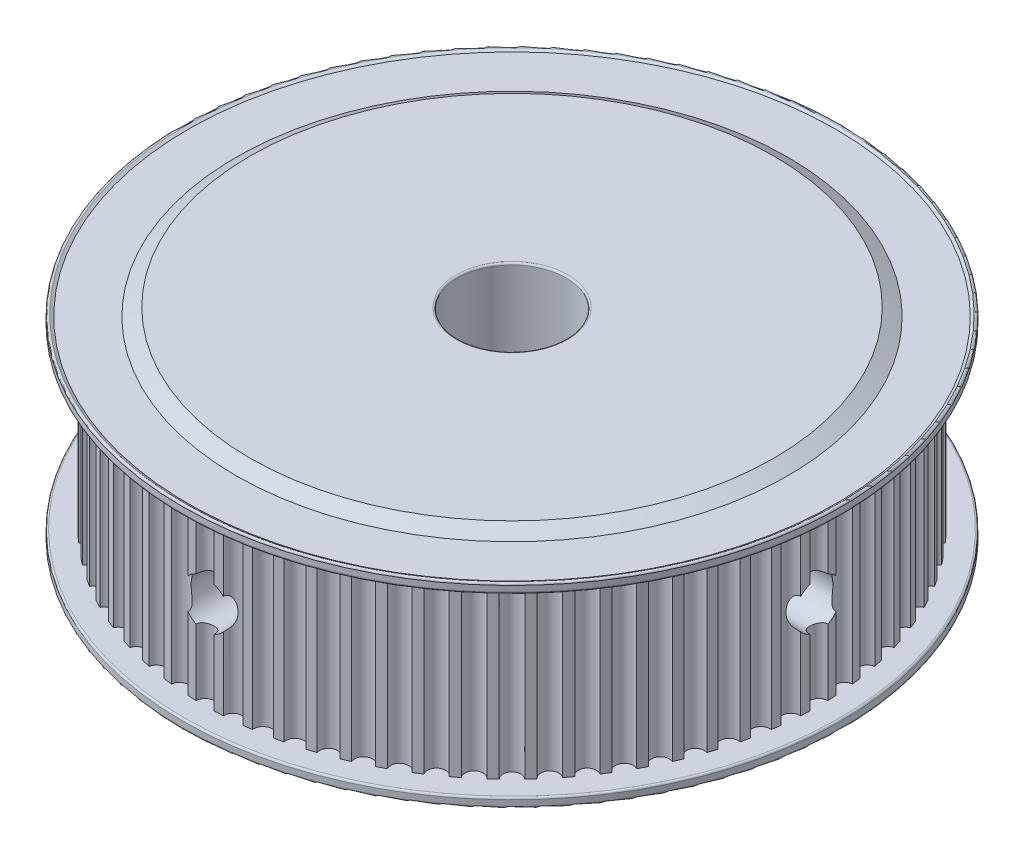
from build123d import *

# Parameters (mm, degrees)
FILLET1_R            = 0.2
BOSS_EXTRUDE1_DEPTH  = 19.5
FILLET1_OF_MIRROR1_R = 0.2
SKETCH4_R            = 2.6
CUT_EXTRUDE1_DEPTH   = 36.5
SKETCH5_R            = 2.6
CUT_EXTRUDE2_DEPTH   = 36.5
SKETCH3_R            = 6
CUT_EXTRUDE3_DEPTH   = 24
FILLET2_R            = 0.2
SCALE1_SCALE         = 0.5


with BuildPart() as part:
    # Sketch1 → Revolve1 (revolve)
    with BuildSketch(Plane.XY):
        Polygon((0, 0), (0, 1.75), (36.5, 1.75), (36.5, 0.55), (35.893782217, 0.9), (30.558845727, 0.9), (29, 0), align=None)
    revolve1 = revolve(axis=Axis((0, 0, 0), (0, 1, 0)))

    # Fillet1
    fillet1_edges = [part.edges().sort_by_distance(p)[0] for p in [
        (-36.5, 0.55, 0),
        (-36.5, 1.75, 0),
    ]]
    fillet(fillet1_edges, radius=FILLET1_R)

    # Sketch2 → Boss-Extrude1 (add)
    with BuildSketch(Plane(origin=(0, 1.75, 0), x_dir=(1, 0, 0), z_dir=(0, 1, 0))):
        with BuildLine():
            ThreePointArc((1.965926579, 33.943116131), (1.48305917, 33.967639534), (0.999891863, 33.985294118))
            ThreePointArc((0.999891863, 33.985294118), (0, 33), (-0.999891863, 33.985294118))
            ThreePointArc((-0.999891863, 33.985294118), (-1.48305917, 33.967639534), (-1.965926579, 33.943116131))
            ThreePointArc((-1.965926579, 33.943116131), (-2.876139511, 32.874425037), (-3.958100524, 33.768823495))
            ThreePointArc((-3.958100524, 33.768823495), (-4.437890535, 33.709125287), (-4.916783132, 33.642610535))
            ThreePointArc((-4.916783132, 33.642610535), (-5.730389863, 32.498655849), (-6.88618565, 33.295351736))
            ThreePointArc((-6.88618565, 33.295351736), (-7.358946874, 33.194064242), (-7.830219997, 33.086064359))
            ThreePointArc((-7.830219997, 33.086064359), (-8.541028488, 31.875552268), (-9.761862745, 32.568482245))
            ThreePointArc((-9.761862745, 32.568482245), (-10.223997183, 32.426376325), (-10.68406416, 32.277713256))
            ThreePointArc((-10.68406416, 32.277713256), (-11.28666473, 31.009856486), (-12.56324617, 31.593746939))
            ThreePointArc((-12.56324617, 31.593746939), (-13.0112367, 31.411904105), (-13.456596143, 31.223709264))
            ThreePointArc((-13.456596143, 31.223709264), (-13.946402637, 29.908156972), (-15.269015706, 30.378564143))
            ThreePointArc((-15.269015706, 30.378564143), (-15.69945285, 30.158368328), (-16.126715305, 29.932073992))
            ThreePointArc((-16.126715305, 29.932073992), (-16.5, 28.578838325), (-17.858578813, 28.93218213))
            ThreePointArc((-17.858578813, 28.93218213), (-18.268186684, 28.675309158), (-18.674100425, 28.412637564))
            ThreePointArc((-18.674100425, 28.412637564), (-18.9280224, 27.032017462), (-20.312227352, 27.265608741))
            ThreePointArc((-20.312227352, 27.265608741), (-20.697888586, 26.97401357), (-21.079364365, 26.676963807))
            ThreePointArc((-21.079364365, 26.676963807), (-21.21199112, 25.279466623), (-22.611287575, 25.391527606))
            ThreePointArc((-22.611287575, 25.391527606), (-22.970067059, 25.067429452), (-23.324201615, 24.738262248))
            ThreePointArc((-23.324201615, 24.738262248), (-23.334523779, 23.334523779), (-24.738262248, 23.324201615))
            ThreePointArc((-24.738262248, 23.324201615), (-25.067429452, 22.970067059), (-25.391527606, 22.611287575))
            ThreePointArc((-25.391527606, 22.611287575), (-25.279466623, 21.21199112), (-26.676963807, 21.079364365))
            ThreePointArc((-26.676963807, 21.079364365), (-26.97401357, 20.697888586), (-27.265608741, 20.312227352))
            ThreePointArc((-27.265608741, 20.312227352), (-27.032017462, 18.9280224), (-28.412637564, 18.674100425))
            ThreePointArc((-28.412637564, 18.674100425), (-28.675309158, 18.268186684), (-28.93218213, 17.858578813))
            ThreePointArc((-28.93218213, 17.858578813), (-28.578838325, 16.5), (-29.932073992, 16.126715305))
            ThreePointArc((-29.932073992, 16.126715305), (-30.158368328, 15.69945285), (-30.378564143, 15.269015706))
            ThreePointArc((-30.378564143, 15.269015706), (-29.908156972, 13.946402637), (-31.223709264, 13.456596143))
            ThreePointArc((-31.223709264, 13.456596143), (-31.411904105, 13.0112367), (-31.593746939, 12.56324617))
            ThreePointArc((-31.593746939, 12.56324617), (-31.009856486, 11.28666473), (-32.277713256, 10.68406416))
            ThreePointArc((-32.277713256, 10.68406416), (-32.426376325, 10.223997183), (-32.568482245, 9.761862745))
            ThreePointArc((-32.568482245, 9.761862745), (-31.875552268, 8.541028488), (-33.086064359, 7.830219997))
            ThreePointArc((-33.086064359, 7.830219997), (-33.194064242, 7.358946874), (-33.295351736, 6.88618565))
            ThreePointArc((-33.295351736, 6.88618565), (-32.498655849, 5.730389863), (-33.642610535, 4.916783132))
            ThreePointArc((-33.642610535, 4.916783132), (-33.709125287, 4.437890535), (-33.768823495, 3.958100524))
            ThreePointArc((-33.768823495, 3.958100524), (-32.874425037, 2.876139511), (-33.943116131, 1.965926579))
            ThreePointArc((-33.943116131, 1.965926579), (-33.967639534, 1.48305917), (-33.985294118, 0.999891863))
            ThreePointArc((-33.985294118, 0.999891863), (-33, 0), (-33.985294118, -0.999891863))
            ThreePointArc((-33.985294118, -0.999891863), (-33.967639534, -1.48305917), (-33.943116131, -1.965926579))
            ThreePointArc((-33.943116131, -1.965926579), (-32.874425037, -2.876139511), (-33.768823495, -3.958100524))
            ThreePointArc((-33.768823495, -3.958100524), (-33.709125287, -4.437890535), (-33.642610535, -4.916783132))
            ThreePointArc((-33.642610535, -4.916783132), (-32.498655849, -5.730389863), (-33.295351736, -6.88618565))
            ThreePointArc((-33.295351736, -6.88618565), (-33.194064242, -7.358946874), (-33.086064359, -7.830219997))
            ThreePointArc((-33.086064359, -7.830219997), (-31.875552268, -8.541028488), (-32.568482245, -9.761862745))
            ThreePointArc((-32.568482245, -9.761862745), (-32.426376325, -10.223997183), (-32.277713256, -10.68406416))
            ThreePointArc((-32.277713256, -10.68406416), (-31.009856486, -11.28666473), (-31.593746939, -12.56324617))
            ThreePointArc((-31.593746939, -12.56324617), (-31.411904105, -13.0112367), (-31.223709264, -13.456596143))
            ThreePointArc((-31.223709264, -13.456596143), (-29.908156972, -13.946402637), (-30.378564143, -15.269015706))
            ThreePointArc((-30.378564143, -15.269015706), (-30.158368328, -15.69945285), (-29.932073992, -16.126715305))
            ThreePointArc((-29.932073992, -16.126715305), (-28.578838325, -16.5), (-28.93218213, -17.858578813))
            ThreePointArc((-28.93218213, -17.858578813), (-28.675309158, -18.268186684), (-28.412637564, -18.674100425))
            ThreePointArc((-28.412637564, -18.674100425), (-27.032017462, -18.9280224), (-27.265608741, -20.312227352))
            ThreePointArc((-27.265608741, -20.312227352), (-26.97401357, -20.697888586), (-26.676963807, -21.079364365))
            ThreePointArc((-26.676963807, -21.079364365), (-25.279466623, -21.21199112), (-25.391527606, -22.611287575))
            ThreePointArc((-25.391527606, -22.611287575), (-25.067429452, -22.970067059), (-24.738262248, -23.324201615))
            ThreePointArc((-24.738262248, -23.324201615), (-23.334523779, -23.334523779), (-23.324201615, -24.738262248))
            ThreePointArc((-23.324201615, -24.738262248), (-22.970067059, -25.067429452), (-22.611287575, -25.391527606))
            ThreePointArc((-22.611287575, -25.391527606), (-21.21199112, -25.279466623), (-21.079364365, -26.676963807))
            ThreePointArc((-21.079364365, -26.676963807), (-20.697888586, -26.97401357), (-20.312227352, -27.265608741))
            ThreePointArc((-20.312227352, -27.265608741), (-18.9280224, -27.032017462), (-18.674100425, -28.412637564))
            ThreePointArc((-18.674100425, -28.412637564), (-18.268186684, -28.675309158), (-17.858578813, -28.93218213))
            ThreePointArc((-17.858578813, -28.93218213), (-16.5, -28.578838325), (-16.126715305, -29.932073992))
            ThreePointArc((-16.126715305, -29.932073992), (-15.69945285, -30.158368328), (-15.269015706, -30.378564143))
            ThreePointArc((-15.269015706, -30.378564143), (-13.946402637, -29.908156972), (-13.456596143, -31.223709264))
            ThreePointArc((-13.456596143, -31.223709264), (-13.0112367, -31.411904105), (-12.56324617, -31.593746939))
            ThreePointArc((-12.56324617, -31.593746939), (-11.28666473, -31.009856486), (-10.68406416, -32.277713256))
            ThreePointArc((-10.68406416, -32.277713256), (-10.223997183, -32.426376325), (-9.761862745, -32.568482245))
            ThreePointArc((-9.761862745, -32.568482245), (-8.541028488, -31.875552268), (-7.830219997, -33.086064359))
            ThreePointArc((-7.830219997, -33.086064359), (-7.358946874, -33.194064242), (-6.88618565, -33.295351736))
            ThreePointArc((-6.88618565, -33.295351736), (-5.730389863, -32.498655849), (-4.916783132, -33.642610535))
            ThreePointArc((-4.916783132, -33.642610535), (-4.437890535, -33.709125287), (-3.958100524, -33.768823495))
            ThreePointArc((-3.958100524, -33.768823495), (-2.876139511, -32.874425037), (-1.965926579, -33.943116131))
            ThreePointArc((-1.965926579, -33.943116131), (-1.48305917, -33.967639534), (-0.999891863, -33.985294118))
            ThreePointArc((-0.999891863, -33.985294118), (0, -33), (0.999891863, -33.985294118))
            ThreePointArc((0.999891863, -33.985294118), (1.48305917, -33.967639534), (1.965926579, -33.943116131))
            ThreePointArc((1.965926579, -33.943116131), (2.876139511, -32.874425037), (3.958100524, -33.768823495))
            ThreePointArc((3.958100524, -33.768823495), (4.437890535, -33.709125287), (4.916783132, -33.642610535))
            ThreePointArc((4.916783132, -33.642610535), (5.730389863, -32.498655849), (6.88618565, -33.295351736))
            ThreePointArc((6.88618565, -33.295351736), (7.358946874, -33.194064242), (7.830219997, -33.086064359))
            ThreePointArc((7.830219997, -33.086064359), (8.541028488, -31.875552268), (9.761862745, -32.568482245))
            ThreePointArc((9.761862745, -32.568482245), (10.223997183, -32.426376325), (10.68406416, -32.277713256))
            ThreePointArc((10.68406416, -32.277713256), (11.28666473, -31.009856486), (12.56324617, -31.593746939))
            ThreePointArc((12.56324617, -31.593746939), (13.0112367, -31.411904105), (13.456596143, -31.223709264))
            ThreePointArc((13.456596143, -31.223709264), (13.946402637, -29.908156972), (15.269015706, -30.378564143))
            ThreePointArc((15.269015706, -30.378564143), (15.69945285, -30.158368328), (16.126715305, -29.932073992))
            ThreePointArc((16.126715305, -29.932073992), (16.5, -28.578838325), (17.858578813, -28.93218213))
            ThreePointArc((17.858578813, -28.93218213), (18.268186684, -28.675309158), (18.674100425, -28.412637564))
            ThreePointArc((18.674100425, -28.412637564), (18.9280224, -27.032017462), (20.312227352, -27.265608741))
            ThreePointArc((20.312227352, -27.265608741), (20.697888586, -26.97401357), (21.079364365, -26.676963807))
            ThreePointArc((21.079364365, -26.676963807), (21.21199112, -25.279466623), (22.611287575, -25.391527606))
            ThreePointArc((22.611287575, -25.391527606), (22.970067059, -25.067429452), (23.324201615, -24.738262248))
            ThreePointArc((23.324201615, -24.738262248), (23.334523779, -23.334523779), (24.738262248, -23.324201615))
            ThreePointArc((24.738262248, -23.324201615), (25.067429452, -22.970067059), (25.391527606, -22.611287575))
            ThreePointArc((25.391527606, -22.611287575), (25.279466623, -21.21199112), (26.676963807, -21.079364365))
            ThreePointArc((26.676963807, -21.079364365), (26.97401357, -20.697888586), (27.265608741, -20.312227352))
            ThreePointArc((27.265608741, -20.312227352), (27.032017462, -18.9280224), (28.412637564, -18.674100425))
            ThreePointArc((28.412637564, -18.674100425), (28.675309158, -18.268186684), (28.93218213, -17.858578813))
            ThreePointArc((28.93218213, -17.858578813), (28.578838325, -16.5), (29.932073992, -16.126715305))
            ThreePointArc((29.932073992, -16.126715305), (30.158368328, -15.69945285), (30.378564143, -15.269015706))
            ThreePointArc((30.378564143, -15.269015706), (29.908156972, -13.946402637), (31.223709264, -13.456596143))
            ThreePointArc((31.223709264, -13.456596143), (31.411904105, -13.0112367), (31.593746939, -12.56324617))
            ThreePointArc((31.593746939, -12.56324617), (31.009856486, -11.28666473), (32.277713256, -10.68406416))
            ThreePointArc((32.277713256, -10.68406416), (32.426376325, -10.223997183), (32.568482245, -9.761862745))
            ThreePointArc((32.568482245, -9.761862745), (31.875552268, -8.541028488), (33.086064359, -7.830219997))
            ThreePointArc((33.086064359, -7.830219997), (33.194064242, -7.358946874), (33.295351736, -6.88618565))
            ThreePointArc((33.295351736, -6.88618565), (32.498655849, -5.730389863), (33.642610535, -4.916783132))
            ThreePointArc((33.642610535, -4.916783132), (33.709125287, -4.437890535), (33.768823495, -3.958100524))
            ThreePointArc((33.768823495, -3.958100524), (32.874425037, -2.876139511), (33.943116131, -1.965926579))
            ThreePointArc((33.943116131, -1.965926579), (33.967639534, -1.48305917), (33.985294118, -0.999891863))
            ThreePointArc((33.985294118, -0.999891863), (33, 0), (33.985294118, 0.999891863))
            ThreePointArc((33.985294118, 0.999891863), (33.967639534, 1.48305917), (33.943116131, 1.965926579))
            ThreePointArc((33.943116131, 1.965926579), (32.874425037, 2.876139511), (33.768823495, 3.958100524))
            ThreePointArc((33.768823495, 3.958100524), (33.709125287, 4.437890535), (33.642610535, 4.916783132))
            ThreePointArc((33.642610535, 4.916783132), (32.498655849, 5.730389863), (33.295351736, 6.88618565))
            ThreePointArc((33.295351736, 6.88618565), (33.194064242, 7.358946874), (33.086064359, 7.830219997))
            ThreePointArc((33.086064359, 7.830219997), (31.875552268, 8.541028488), (32.568482245, 9.761862745))
            ThreePointArc((32.568482245, 9.761862745), (32.426376325, 10.223997183), (32.277713256, 10.68406416))
            ThreePointArc((32.277713256, 10.68406416), (31.009856486, 11.28666473), (31.593746939, 12.56324617))
            ThreePointArc((31.593746939, 12.56324617), (31.411904105, 13.0112367), (31.223709264, 13.456596143))
            ThreePointArc((31.223709264, 13.456596143), (29.908156972, 13.946402637), (30.378564143, 15.269015706))
            ThreePointArc((30.378564143, 15.269015706), (30.158368328, 15.69945285), (29.932073992, 16.126715305))
            ThreePointArc((29.932073992, 16.126715305), (28.578838325, 16.5), (28.93218213, 17.858578813))
            ThreePointArc((28.93218213, 17.858578813), (28.675309158, 18.268186684), (28.412637564, 18.674100425))
            ThreePointArc((28.412637564, 18.674100425), (27.032017462, 18.9280224), (27.265608741, 20.312227352))
            ThreePointArc((27.265608741, 20.312227352), (26.97401357, 20.697888586), (26.676963807, 21.079364365))
            ThreePointArc((26.676963807, 21.079364365), (25.279466623, 21.21199112), (25.391527606, 22.611287575))
            ThreePointArc((25.391527606, 22.611287575), (25.067429452, 22.970067059), (24.738262248, 23.324201615))
            ThreePointArc((24.738262248, 23.324201615), (23.334523779, 23.334523779), (23.324201615, 24.738262248))
            ThreePointArc((23.324201615, 24.738262248), (22.970067059, 25.067429452), (22.611287575, 25.391527606))
            ThreePointArc((22.611287575, 25.391527606), (21.21199112, 25.279466623), (21.079364365, 26.676963807))
            ThreePointArc((21.079364365, 26.676963807), (20.697888586, 26.97401357), (20.312227352, 27.265608741))
            ThreePointArc((20.312227352, 27.265608741), (18.9280224, 27.032017462), (18.674100425, 28.412637564))
            ThreePointArc((18.674100425, 28.412637564), (18.268186684, 28.675309158), (17.858578813, 28.93218213))
            ThreePointArc((17.858578813, 28.93218213), (16.5, 28.578838325), (16.126715305, 29.932073992))
            ThreePointArc((16.126715305, 29.932073992), (15.69945285, 30.158368328), (15.269015706, 30.378564143))
            ThreePointArc((15.269015706, 30.378564143), (13.946402637, 29.908156972), (13.456596143, 31.223709264))
            ThreePointArc((13.456596143, 31.223709264), (13.0112367, 31.411904105), (12.56324617, 31.593746939))
            ThreePointArc((12.56324617, 31.593746939), (11.28666473, 31.009856486), (10.68406416, 32.277713256))
            ThreePointArc((10.68406416, 32.277713256), (10.223997183, 32.426376325), (9.761862745, 32.568482245))
            ThreePointArc((9.761862745, 32.568482245), (8.541028488, 31.875552268), (7.830219997, 33.086064359))
            ThreePointArc((7.830219997, 33.086064359), (7.358946874, 33.194064242), (6.88618565, 33.295351736))
            ThreePointArc((6.88618565, 33.295351736), (5.730389863, 32.498655849), (4.916783132, 33.642610535))
            ThreePointArc((4.916783132, 33.642610535), (4.437890535, 33.709125287), (3.958100524, 33.768823495))
            ThreePointArc((3.958100524, 33.768823495), (2.876139511, 32.874425037), (1.965926579, 33.943116131))
        make_face()
    extrude(amount=BOSS_EXTRUDE1_DEPTH)

    # Mirror1: Revolve1 across plane
    add(revolve1.mirror(Plane.ZX.offset(11.5)))

    # Fillet1 of Mirror1
    fillet1_of_mirror1_edges = [part.edges().sort_by_distance(p)[0] for p in [
        (-36.5, 22.45, 0),
        (-36.5, 21.25, 0),
    ]]
    fillet(fillet1_of_mirror1_edges, radius=FILLET1_OF_MIRROR1_R)

    # Sketch4 → Cut-Extrude1 (cut)
    with BuildSketch(Plane.XY):
        with Locations((0, 11.5)):
            Circle(SKETCH4_R)
    extrude(amount=CUT_EXTRUDE1_DEPTH, mode=Mode.SUBTRACT)

    # Sketch5 → Cut-Extrude2 (cut)
    with BuildSketch(Plane(origin=(0, 0, 0), x_dir=(0, 0, -1), z_dir=(1, 0, 0))):
        with Locations((0, 11.5)):
            Circle(SKETCH5_R)
    extrude(amount=CUT_EXTRUDE2_DEPTH, mode=Mode.SUBTRACT)

    # Sketch3 → Cut-Extrude3 (cut, through all)
    with BuildSketch(Plane(origin=(0, 23, 0), x_dir=(1, 0, 0), z_dir=(0, 1, 0))):
        Circle(SKETCH3_R)
    extrude(amount=-CUT_EXTRUDE3_DEPTH, mode=Mode.SUBTRACT)

    # Fillet2
    fillet2_edges = [part.edges().sort_by_distance(p)[0] for p in [
        (-6, 0, 0),
        (-6, 23, 0),
    ]]
    fillet(fillet2_edges, radius=FILLET2_R)


with BuildPart() as part_1:
    # Scale1: scaled about (-0.150087732, 11.500000022, -0.150087739)
    add(part.part.scale(SCALE1_SCALE).moved(Location((-0.075043866, 5.750000011, -0.075043869))))


solid = part_1.part
